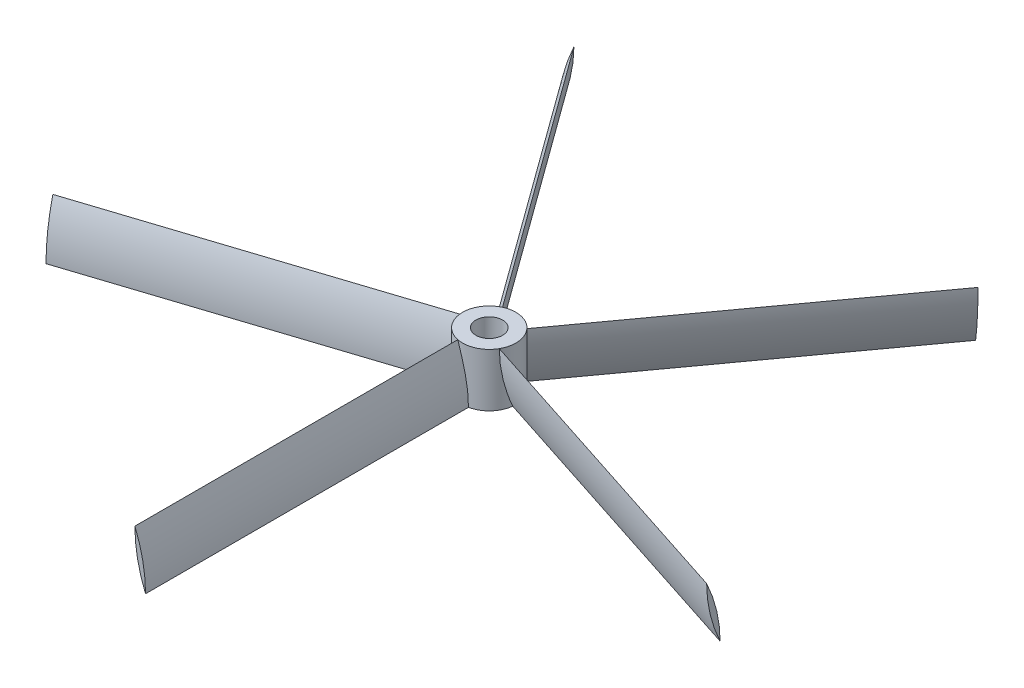
from build123d import *

# Parameters (mm, degrees)
SKETCH_1_R               = 5
SKETCH_1_R_2             = 2.5
EXTRUDE_1_DEPTH          = 10
EXTRUDE_START            = 4
EXTRUDE_2_DEPTH          = 61.5
PATTERN_CIRCULAR_1_COUNT = 5


with BuildPart() as part:
    # 草图1 → 凸台-拉伸1 (new body)
    with BuildSketch(Plane(origin=(0, 0, 0), x_dir=(1, 0, 0), z_dir=(0, 1, 0))):
        Circle(SKETCH_1_R)
        Circle(SKETCH_1_R_2, mode=Mode.SUBTRACT)
    extrude(amount=EXTRUDE_1_DEPTH)

    # 草图2 → 凸台-拉伸2 (add)
    with BuildSketch(Plane.XY.offset(EXTRUDE_START)):
        with BuildLine():
            ThreePointArc((-1, 10), (-0.495097568, 4.900980486), (1, 0))
            ThreePointArc((1, 0), (0.495097568, 5.099019514), (-1, 10))
        make_face()
    extrude_2 = extrude(amount=EXTRUDE_2_DEPTH)

    # 阵列(圆周)1: 凸台-拉伸2 ×5 about axis
    pattern_circular_1_axis = Axis((0, 0, 0), (0, 1, 0))
    for i in range(1, PATTERN_CIRCULAR_1_COUNT):
        add(extrude_2.rotate(pattern_circular_1_axis, i * 360 / PATTERN_CIRCULAR_1_COUNT))


solid = part.part
